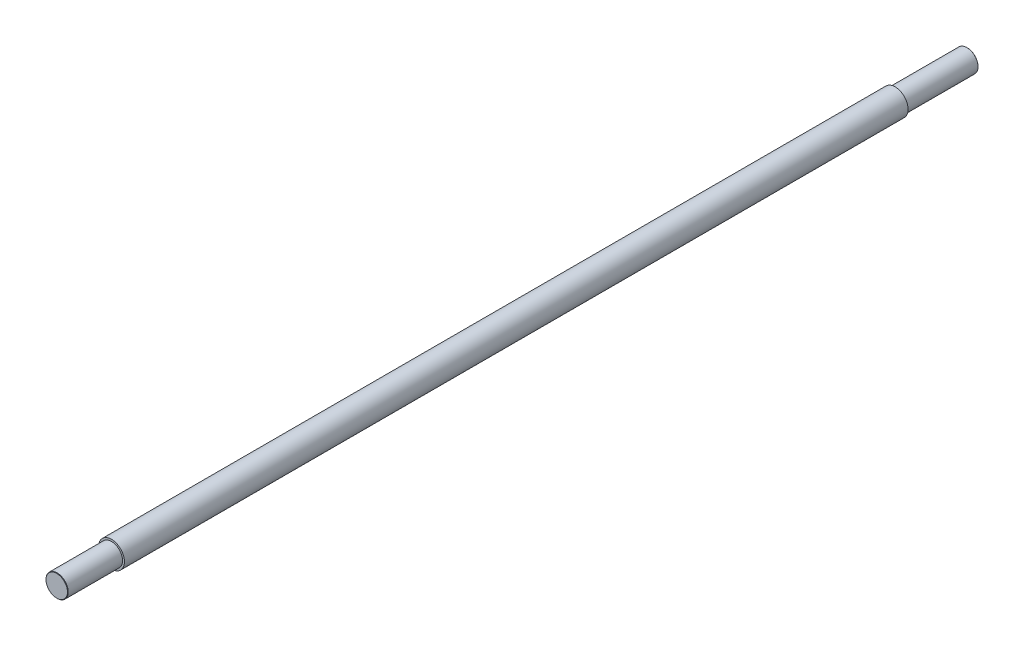
from build123d import *

# Parameters (mm, degrees)
CHAMFER_1_SIZE = 1
CHAMFER_2_SIZE = 1


with BuildPart() as part:
    # 草图1 → 旋转1 (revolve)
    with BuildSketch(Plane(origin=(0, 0, 0), x_dir=(0, 0, -1), z_dir=(1, 0, 0))):
        Polygon((0, 0), (0, 30), (148, 30), (148, 35), (2266, 35), (2266, 30), (2461, 30), (2461, 0), align=None)
    revolve(axis=Axis((0, 0, 0), (0, 0, -1)))

    # 倒角1
    chamfer_1_edges = [part.edges().sort_by_distance(p)[0] for p in [
        (0, -30, -2461),
    ]]
    chamfer(chamfer_1_edges, length=CHAMFER_1_SIZE)

    # 倒角2
    chamfer_2_edges = [part.edges().sort_by_distance(p)[0] for p in [
        (0, -30, 0),
    ]]
    chamfer(chamfer_2_edges, length=CHAMFER_2_SIZE)


solid = part.part
